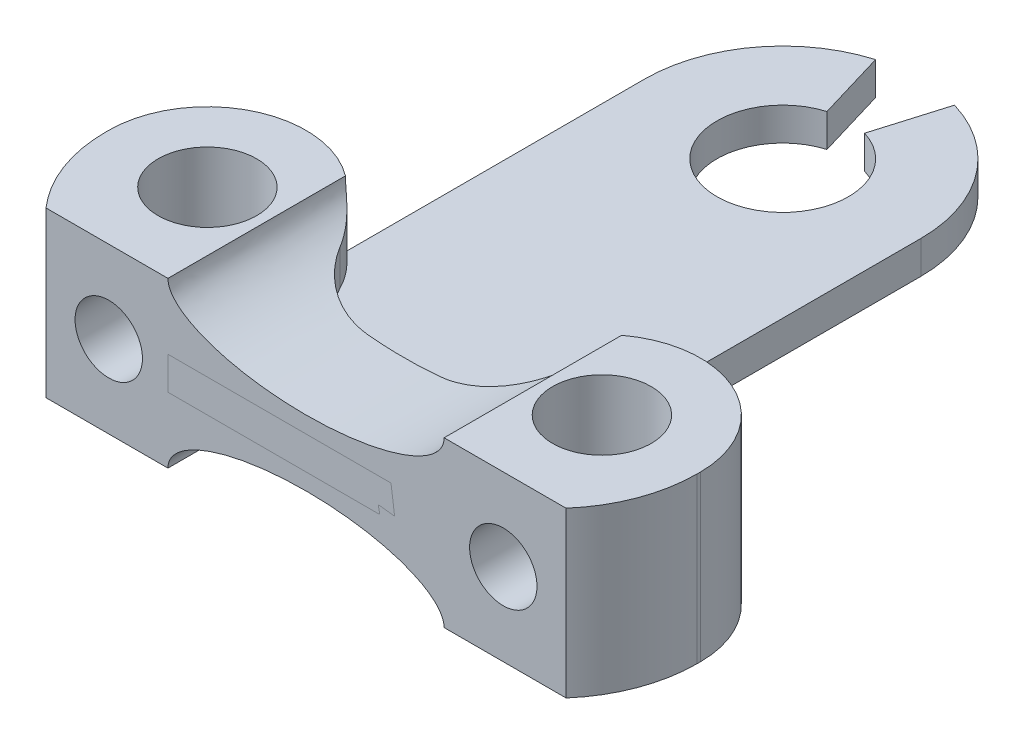
from build123d import *

# Parameters (mm, degrees)
BOSS_EXTRUDE1_DEPTH     = 1
BOSS_EXTRUDE2_START     = -3
SKETCH3_R               = 1.5
BOSS_EXTRUDE2_DEPTH     = 5
CUT_EXTRUDE1_START      = -3.40484
SKETCH4_R               = 1.025
CUT_EXTRUDE1_DEPTH      = 3.388831
SKETCH5_RX              = 4.2
SKETCH5_RY              = 1.5
CUT_EXTRUDE2_DEPTH      = 16.524922359
CUT_EXTRUDE2_DEPTH_BACK = 5.5000001
SKETCH6_W               = 18
SKETCH6_H               = 1.5
CUT_EXTRUDE3_DEPTH      = 5


with BuildPart() as part:
    # Sketch2 → Boss-Extrude1 (new body)
    with BuildSketch(Plane(origin=(0, 0, 0), x_dir=(1, 0, 0), z_dir=(0, 1, 0))):
        with BuildLine():
            Line((-0.571428571, 19.113275972), (-1.2, 21.221568636))
            ThreePointArc((-1.2, 21.221568636), (-3.367491648, 19.706626356), (-4.2, 17.196646277))
            Line((-4.2, 17.196646277), (-4.2, 1.196646277))
            Line((-4.2, 1.196646277), (4.2, 1.196646277))
            Line((4.2, 1.196646277), (4.2, 17.196646277))
            ThreePointArc((4.2, 17.196646277), (3.367491648, 19.706626356), (1.2, 21.221568636))
            Line((1.2, 21.221568636), (0.571428571, 19.113275972))
            ThreePointArc((0.571428571, 19.113275972), (0, 15.196646277), (-0.571428571, 19.113275972))
        make_face()
    extrude(amount=BOSS_EXTRUDE1_DEPTH)


with BuildPart() as body_2:
    # Sketch3 → Boss-Extrude2 (new body)
    with BuildSketch(Plane.XZ.offset(BOSS_EXTRUDE2_START)):
        with BuildLine():
            ThreePointArc((9, -5.596646277), (7.711269837, -2.485376439), (4.6, -1.196646277))
            Line((4.6, -1.196646277), (-4.6, -1.196646277))
            ThreePointArc((-4.6, -1.196646277), (-7.711269837, -2.485376439), (-9, -5.596646277))
            Line((-9, -5.596646277), (-9, -5.696646277))
            ThreePointArc((-9, -5.696646277), (-8.121320344, -7.81796662), (-6, -8.696646277))
            ThreePointArc((-6, -8.696646277), (-4.433301096, -8.255054873), (-3.327829372, -7.06028264))
            ThreePointArc((-3.327829372, -7.06028264), (-2.406602934, -6.064639113), (-1.101020514, -5.696646277))
            Line((-1.101020514, -5.696646277), (1.101020514, -5.696646277))
            ThreePointArc((1.101020514, -5.696646277), (2.406602934, -6.064639113), (3.327829372, -7.06028264))
            ThreePointArc((3.327829372, -7.06028264), (4.433301096, -8.255054873), (6, -8.696646277))
            ThreePointArc((6, -8.696646277), (8.121320344, -7.81796662), (9, -5.696646277))
            Line((9, -5.696646277), (9, -5.596646277))
        make_face()
        with Locations((-6, -5.696646277)):
            Circle(SKETCH3_R, mode=Mode.SUBTRACT)
        with Locations((6, -5.696646277)):
            Circle(SKETCH3_R, mode=Mode.SUBTRACT)
    extrude(amount=BOSS_EXTRUDE2_DEPTH)

    # Sketch4 → Cut-Extrude1 (cut)
    with BuildSketch(Plane.XY.offset(-1.196646277).offset(CUT_EXTRUDE1_START)):
        with Locations((-6, 0.5)):
            Circle(SKETCH4_R)
        with Locations((6, 0.5)):
            Circle(SKETCH4_R)
    extrude(amount=CUT_EXTRUDE1_DEPTH, mode=Mode.SUBTRACT)

    # Sketch5 → Cut-Extrude2 (cut, two sides)
    with BuildSketch(Plane(origin=(0, 0, -5.696646277), x_dir=(-1, 0, 0), z_dir=(0, 0, -1))) as cut_extrude2_sk:
        with Locations(Location((0, 3), (0, 0, 180))):
            Ellipse(SKETCH5_RX, SKETCH5_RY)
        with Locations((0, -2)):
            Ellipse(SKETCH5_RX, SKETCH5_RY)
    extrude(amount=CUT_EXTRUDE2_DEPTH, mode=Mode.SUBTRACT)
    extrude(cut_extrude2_sk.sketch, amount=-CUT_EXTRUDE2_DEPTH_BACK, mode=Mode.SUBTRACT)


with BuildPart() as cut_extrude3_tool:
    # Sketch6 → Cut-Extrude3 (new body)
    with BuildSketch(Plane.XZ.offset(2)):
        with Locations((0, -1.946646277)):
            Rectangle(SKETCH6_W, SKETCH6_H)
    extrude(amount=-CUT_EXTRUDE3_DEPTH)


with BuildPart() as part_1:
    add(part.part)

    # Cut-Extrude3: cut by cut_extrude3_tool
    add(cut_extrude3_tool.part, mode=Mode.SUBTRACT)


with BuildPart() as body_2_1:
    add(body_2.part)

    # Cut-Extrude3: cut by cut_extrude3_tool
    add(cut_extrude3_tool.part, mode=Mode.SUBTRACT)


solid = Compound([part_1.part, body_2_1.part])
